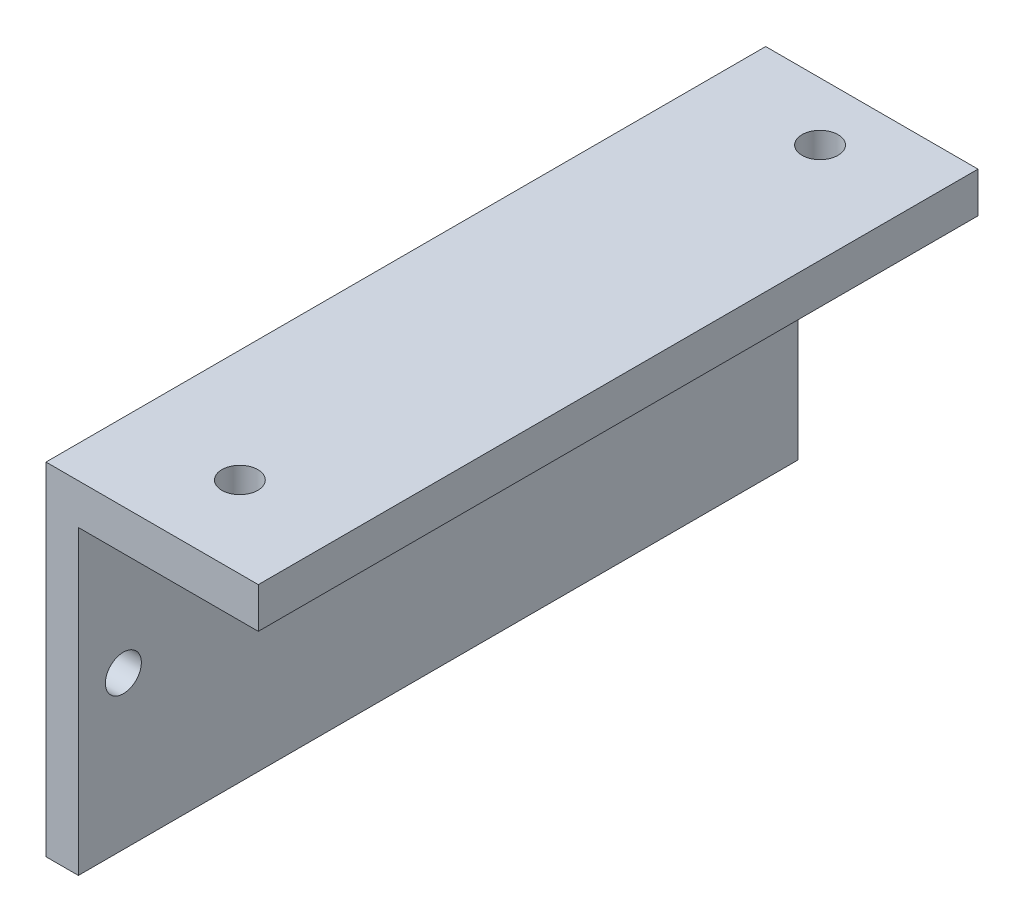
from build123d import *

# Parameters (mm, degrees)
SKETCH1_W           = 80
SKETCH1_H           = 4.5
BOSS_EXTRUDE1_DEPTH = 23.6
SKETCH1_4_W         = 80
SKETCH1_4_H         = 33.5
SKETCH1_4_R         = 2
BOSS_EXTRUDE2_DEPTH = 3.6
CUT_EXTRUDE1_REACH  = 62.008
SKETCH2_R           = 2


with BuildPart() as part:
    # Sketch1 → Boss-Extrude1 (new body)
    with BuildSketch(Plane(origin=(0, 0, 0), x_dir=(0, 0, -1), z_dir=(1, 0, 0))):
        with Locations((0, 16.75)):
            Rectangle(SKETCH1_W, SKETCH1_H)
    extrude(amount=BOSS_EXTRUDE1_DEPTH)

    # Sketch1_4 → Boss-Extrude2 (add)
    with BuildSketch(Plane(origin=(0, 0, 0), x_dir=(0, 0, -1), z_dir=(1, 0, 0))):
        with Locations((0, -2.25)):
            Rectangle(SKETCH1_4_W, SKETCH1_4_H)
        with Locations((-35, -2)):
            Circle(SKETCH1_4_R, mode=Mode.SUBTRACT)
        with Locations((35, -2)):
            Circle(SKETCH1_4_R, mode=Mode.SUBTRACT)
    extrude(amount=BOSS_EXTRUDE2_DEPTH)

    # Sketch2 → Cut-Extrude1 (cut, up to next)
    with BuildSketch(Plane(origin=(0, 19, 0), x_dir=(1, 0, 0), z_dir=(0, 1, 0)), mode=Mode.PRIVATE) as cut_extrude1_sk1:
        with Locations((12.5, 33.54131816)):
            Circle(SKETCH2_R)
    cut_extrude1_tool1 = extrude(cut_extrude1_sk1.sketch, amount=-CUT_EXTRUDE1_REACH, mode=Mode.PRIVATE) & part.part
    # Sketch2 → Cut-Extrude1 (cut, up to next)
    with BuildSketch(Plane(origin=(0, 19, 0), x_dir=(1, 0, 0), z_dir=(0, 1, 0)), mode=Mode.PRIVATE) as cut_extrude1_sk2:
        with Locations((12.5, -30.950875555)):
            Circle(SKETCH2_R)
    cut_extrude1_tool2 = extrude(cut_extrude1_sk2.sketch, amount=-CUT_EXTRUDE1_REACH, mode=Mode.PRIVATE) & part.part
    add(cut_extrude1_tool1.solids().sort_by_distance((12.5, 19, -33.541318))[0], mode=Mode.SUBTRACT)
    add(cut_extrude1_tool2.solids().sort_by_distance((12.5, 19, 30.950876))[0], mode=Mode.SUBTRACT)


solid = part.part
